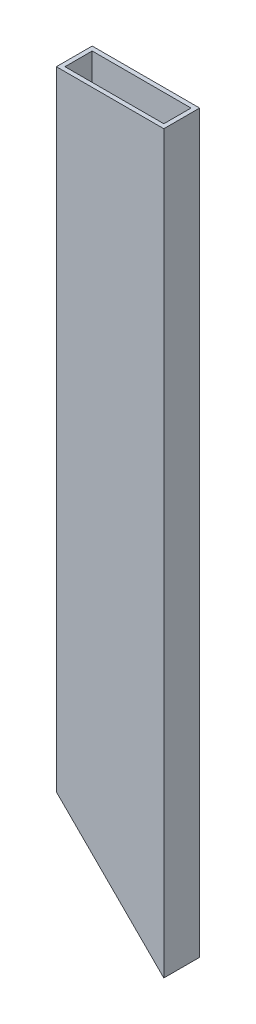
from build123d import *

# Parameters (mm, degrees)
SKETCH1_W               = 76.2
SKETCH1_H               = 25.4
SKETCH1_W_2             = 70.104
SKETCH1_H_2             = 19.304
BOSS_EXTRUDE1_DEPTH     = 445.4
SKETCH3_W               = 76.2
SKETCH3_H               = 25.4
SKETCH3_W_2             = 70.104
SKETCH3_H_2             = 19.304
BOSS_EXTRUDE2_DEPTH     = 38.1
SKETCH4_W               = 76.2
SKETCH4_H               = 25.4
SKETCH4_W_2             = 70.104
SKETCH4_H_2             = 19.304
BOSS_EXTRUDE3_DEPTH     = 38.1
CUT_EXTRUDE1_DEPTH      = 13.7
CUT_EXTRUDE1_DEPTH_BACK = 13.7


with BuildPart() as part:
    # Sketch1 → Boss-Extrude1 (new body)
    with BuildSketch(Plane(origin=(0, 0, 0), x_dir=(1, 0, 0), z_dir=(0, 1, 0))):
        Rectangle(SKETCH1_W, SKETCH1_H)
        Rectangle(SKETCH1_W_2, SKETCH1_H_2, mode=Mode.SUBTRACT)
    extrude(amount=BOSS_EXTRUDE1_DEPTH)

    # Sketch3 → Boss-Extrude2 (add)
    with BuildSketch(Plane.XZ):
        Rectangle(SKETCH3_W, SKETCH3_H)
        Rectangle(SKETCH3_W_2, SKETCH3_H_2, mode=Mode.SUBTRACT)
    extrude(amount=BOSS_EXTRUDE2_DEPTH)

    # Sketch4 → Boss-Extrude3 (add)
    with BuildSketch(Plane(origin=(0, 445.4, 0), x_dir=(1, 0, 0), z_dir=(0, 1, 0))):
        Rectangle(SKETCH4_W, SKETCH4_H)
        Rectangle(SKETCH4_W_2, SKETCH4_H_2, mode=Mode.SUBTRACT)
    extrude(amount=BOSS_EXTRUDE3_DEPTH)

    # Sketch5 → Cut-Extrude1 (cut, two sides)
    with BuildSketch(Plane(origin=(-500, 0, 0), x_dir=(1, 0, 0), z_dir=(0, 0, -1))) as cut_extrude1_sk:
        Polygon((607.156068895, 107.156068895), (437.011376746, -62.988623254), (437.011376746, 107.156068895), align=None)
    extrude(amount=CUT_EXTRUDE1_DEPTH, mode=Mode.SUBTRACT)
    extrude(cut_extrude1_sk.sketch, amount=-CUT_EXTRUDE1_DEPTH_BACK, mode=Mode.SUBTRACT)


solid = part.part
